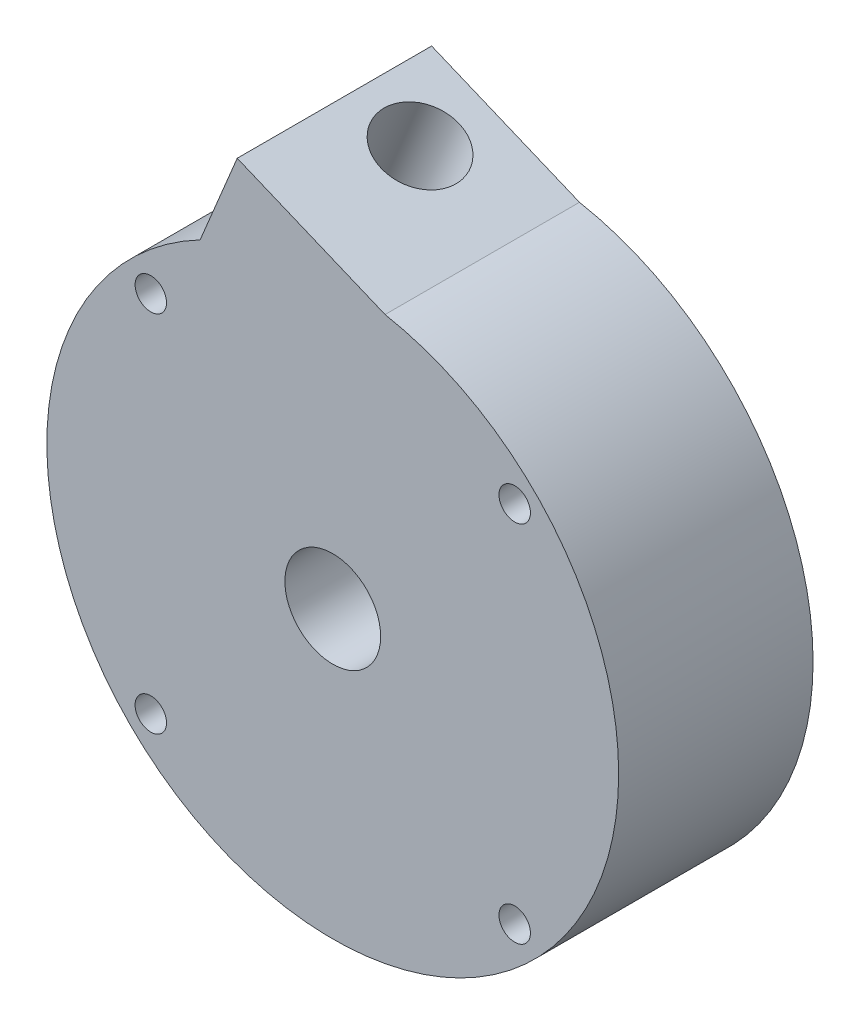
from build123d import *

# Parameters (mm, degrees)
SKETCH3_R                     = 50
SKETCH3_R_2                   = 2.75
EXTRUDE1_DEPTH                = 34
CUT_EXTRUDE2_DEPTH            = 20
EXTRUDE6_DEPTH                = 34
M16_75_16_75_DIAMETER_HOLE1_D = 16.75
CUT_EXTRUDE3_REACH            = 116.262
SKETCH22_R                    = 6.8


with BuildPart() as part:
    # Sketch3 → Extrude1 (new body)
    with BuildSketch(Plane.XY):
        Circle(SKETCH3_R)
        with Locations((31.819805153, -31.819805153)):
            Circle(SKETCH3_R_2, mode=Mode.SUBTRACT)
        with Locations((-31.819805153, -31.819805153)):
            Circle(SKETCH3_R_2, mode=Mode.SUBTRACT)
        with Locations((31.819805153, 31.819805153)):
            Circle(SKETCH3_R_2, mode=Mode.SUBTRACT)
        with Locations((-31.819805153, 31.819805153)):
            Circle(SKETCH3_R_2, mode=Mode.SUBTRACT)
    extrude(amount=EXTRUDE1_DEPTH)

    # Sketch3_6 → Cut-Extrude2 (cut)
    with BuildSketch(Plane.XY):
        with BuildLine():
            Line((-20.421328258, 43.144950309), (-27.237880936, 26.740610009))
            ThreePointArc((-27.237880936, 26.740610009), (-28.54324707, 23.999538948), (-30.118972052, 21.404439318))
            add(Edge.make_bspline(
                [(-8.411618966, 31.392589354), (-6.594986557, 31.927343906), (-4.727596656, 32.304011663), (-0.947579394, 32.726950043), (0.964989801, 32.773208373), (4.777108777, 32.531081057), (6.676598891, 32.242693441), (10.404207822, 31.337263886), (12.232267294, 30.720230446), (15.760360448, 29.173637758), (17.460336939, 28.244097303), (20.679062247, 26.098347596), (22.197757805, 24.882166939), (25.005835643, 22.198009273), (26.295170268, 20.730069861), (28.60307704, 17.585286262), (29.621608652, 15.90848759), (31.354425209, 12.395644964), (32.068678043, 10.559653108), (33.168512452, 6.783381836), (33.554071399, 4.84315955), (33.981977998, 0.91703866), (34.024313279, -1.068799499), (33.761644813, -5.025657895), (33.456639413, -6.996616206), (32.505786005, -10.863180522), (31.859947203, -12.758725015), (30.244434466, -16.415746217), (29.274780398, -18.177163724), (27.038718465, -21.510852538), (25.772340603, -23.083068793), (22.979235835, -25.988634722), (21.452548225, -27.321935222), (18.18350905, -29.706877352), (16.441204938, -30.758477245), (12.792592203, -32.545523582), (10.886337796, -33.28093707), (6.966927518, -34.410539179), (4.95383101, -34.804704707), (0.881572969, -35.237007362), (-1.17752584, -35.275132047), (-5.279057127, -34.991353155), (-7.321425423, -34.669448256), (-11.326780574, -33.672621975), (-13.289703752, -32.997710517), (-17.075395447, -31.312765708), (-18.898102754, -30.302753307), (-22.346412369, -27.975919739), (-23.971957836, -26.659129989), (-26.974594454, -23.756685335), (-28.351634915, -22.171071432), (-30.813133029, -18.777462502), (-31.89754775, -16.969516871), (-33.738297145, -13.184908034), (-34.494598024, -11.208301165), (-35.653409825, -7.145620969), (-36.055897198, -5.05960924), (-36.492023631, -0.841182208), (-36.525650191, 1.29116809), (-36.220191785, 5.537304064), (-35.881105833, 7.651023301), (-34.837758132, 11.795003117), (-34.13350703, 13.825197856), (-32.378618873, 17.739300975), (-31.328003859, 19.623146143), (-30.118972052, 21.404439318)],
                knots=[0, 0, 0, 0, 0.03125, 0.03125, 0.0625, 0.0625, 0.09375, 0.09375, 0.125, 0.125, 0.15625, 0.15625, 0.1875, 0.1875, 0.21875, 0.21875, 0.25, 0.25, 0.28125, 0.28125, 0.3125, 0.3125, 0.34375, 0.34375, 0.375, 0.375, 0.40625, 0.40625, 0.4375, 0.4375, 0.46875, 0.46875, 0.5, 0.5, 0.53125, 0.53125, 0.5625, 0.5625, 0.59375, 0.59375, 0.625, 0.625, 0.65625, 0.65625, 0.6875, 0.6875, 0.71875, 0.71875, 0.75, 0.75, 0.78125, 0.78125, 0.8125, 0.8125, 0.84375, 0.84375, 0.875, 0.875, 0.90625, 0.90625, 0.9375, 0.9375, 0.96875, 0.96875, 1, 1, 1, 1], degree=3))
            Line((-8.411618966, 31.392589354), (-6.015539335, 37.158862647))
            Line((-6.015539335, 37.158862647), (-20.421328258, 43.144950309))
        make_face()
    extrude(amount=CUT_EXTRUDE2_DEPTH, mode=Mode.SUBTRACT)

    # Sketch3_7 → Extrude6 (add)
    with BuildSketch(Plane.XY):
        with BuildLine():
            ThreePointArc((-23.191672282, 44.296121013), (-21.196140075, 45.284916318), (-19.158555872, 46.183868795))
            ThreePointArc((-19.158555872, 46.183868795), (-10.101449269, 48.968977145), (-0.681547061, 49.99535472))
            ThreePointArc((-0.681547061, 49.99535472), (4.254411372, 49.818671037), (9.148855424, 49.155858699))
            Line((9.148855424, 49.155858699), (-16.707688798, 59.900118605))
            Line((-16.707688798, 59.900118605), (-23.191672282, 44.296121013))
        make_face()
    extrude(amount=EXTRUDE6_DEPTH)

    # M16.75 _16.75_ Diameter Hole1 (through all)
    with Locations(Plane.XY.offset(34)):
        with Locations((0, 0)):
            Hole(M16_75_16_75_DIAMETER_HOLE1_D / 2)

    # Sketch22 → Cut-Extrude3 (cut, up to next)
    with BuildSketch(Plane(origin=(18.765429823, 45.159850034, 0), x_dir=(-0.923448008, 0.383723568, 0), z_dir=(0.383723568, 0.923448008, 0)), mode=Mode.PRIVATE) as cut_extrude3_sk1:
        with Locations((27.613769175, 12)):
            Circle(SKETCH22_R)
    cut_extrude3_tool1 = extrude(cut_extrude3_sk1.sketch, amount=-CUT_EXTRUDE3_REACH, mode=Mode.PRIVATE) & part.part
    add(cut_extrude3_tool1.solids().sort_by_distance((-6.73445, 55.755904, 12))[0], mode=Mode.SUBTRACT)


solid = part.part
